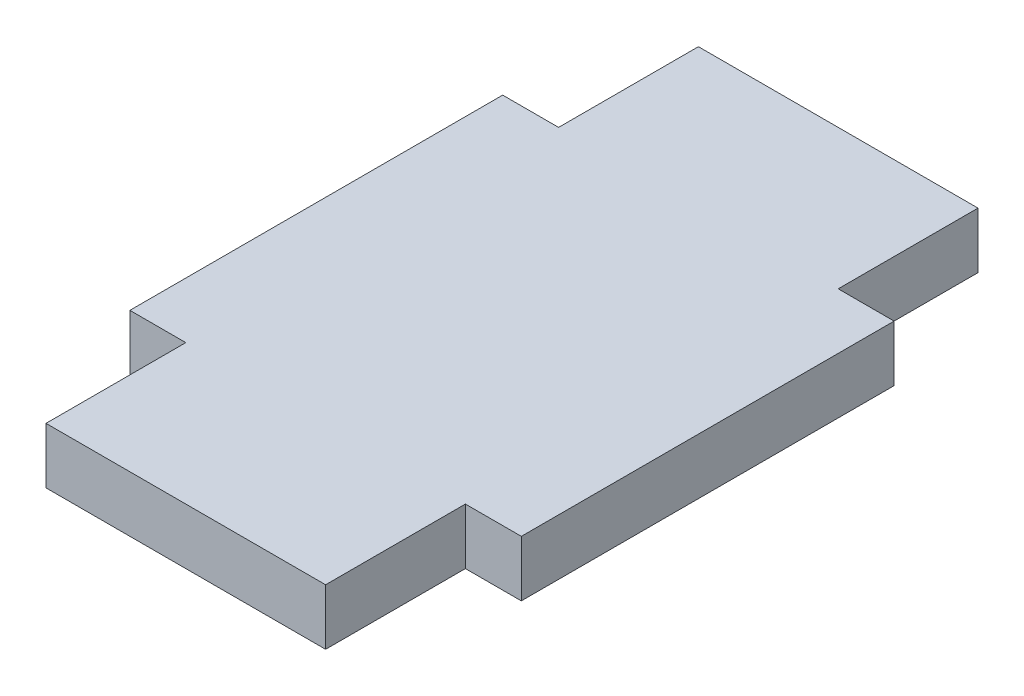
from build123d import *

# Parameters (mm, degrees)
BOSS_EXTRUDE1_DEPTH = 1.5


with BuildPart() as part:
    # Sketch2 → Boss-Extrude1 (new body, symmetric)
    with BuildSketch(Plane(origin=(0, 0, 0), x_dir=(1, 0, 0), z_dir=(0, 1, 0))):
        Polygon((-10.5, 10), (-7.5, 10), (-7.5, 17.5), (7.5, 17.5), (7.5, 10), (10.5, 10), (10.5, -10), (7.5, -10), (7.5, -17.5), (-7.5, -17.5), (-7.5, -10), (-10.5, -10), align=None)
    extrude(amount=BOSS_EXTRUDE1_DEPTH, both=True)


solid = part.part
